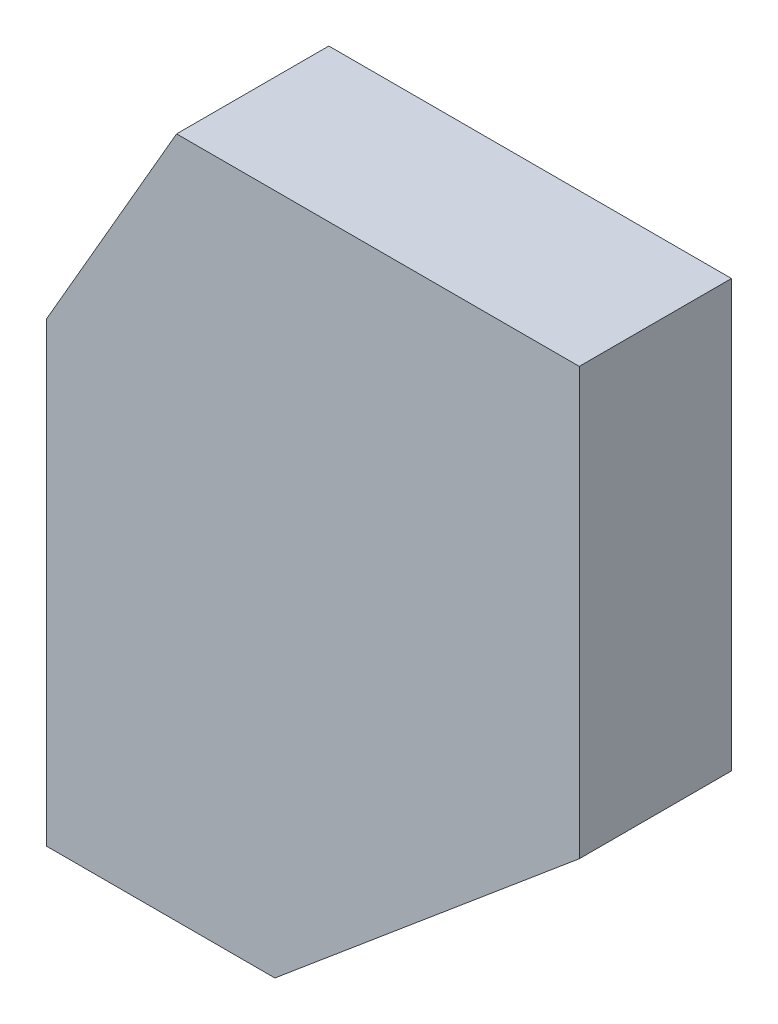
from build123d import *

# Parameters (mm, degrees)
BOSS_EXTRUDE1_DEPTH = 12.7


with BuildPart() as part:
    # Sketch1 → Boss-Extrude1 (new body)
    with BuildSketch(Plane.XY):
        Polygon((0, 0), (19.05, 0), (44.45, 21.313130632), (44.45, 56.896), (10.85187566, 56.896), (0, 38.1), align=None)
    extrude(amount=BOSS_EXTRUDE1_DEPTH)


solid = part.part
